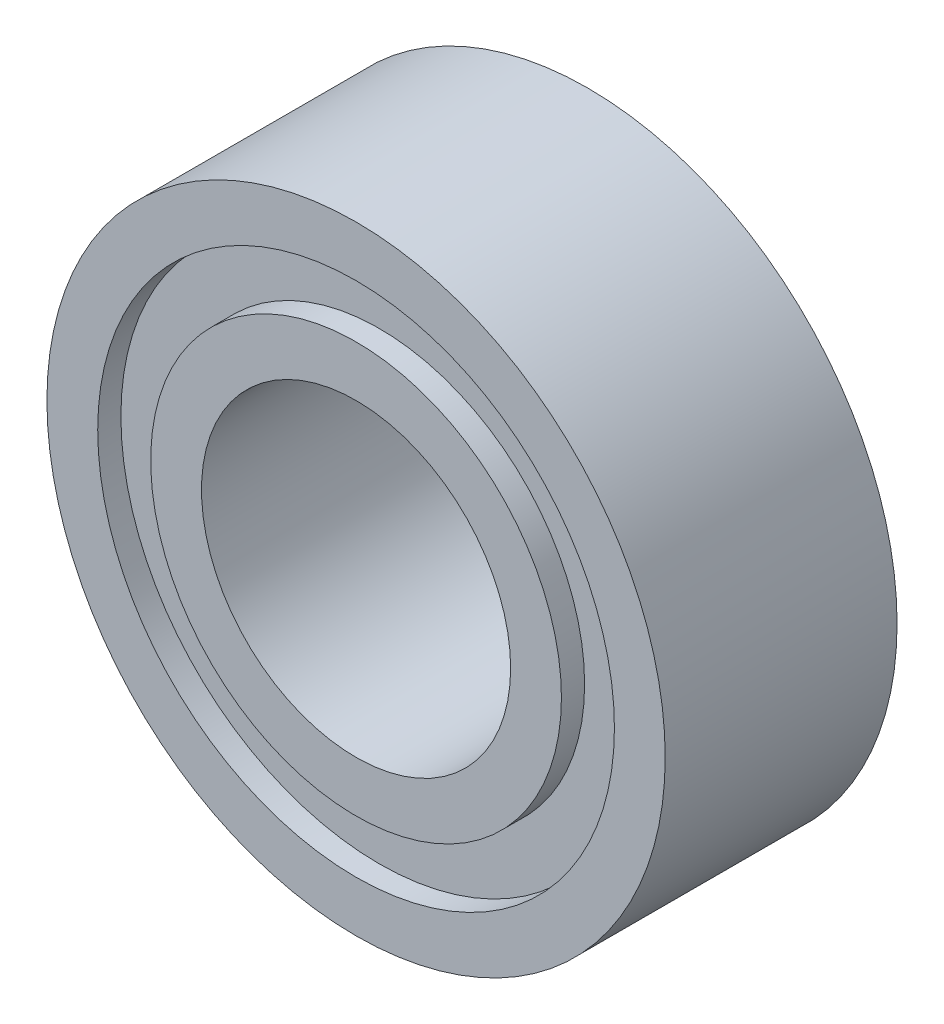
from build123d import *


with BuildPart() as part:
    # Эскиз1 → Повернуть1 (revolve)
    with BuildSketch(Plane(origin=(0, 0, 0), x_dir=(0, 0, -1), z_dir=(1, 0, 0))):
        Polygon((1.5, 2), (-1.5, 2), (-1.5, 2.657142857), (-1.2, 2.657142857), (-1.2, 3.342857143), (-1.5, 3.342857143), (-1.5, 4), (1.5, 4), (1.5, 3.342857143), (1.2, 3.342857143), (1.2, 2.657142857), (1.5, 2.657142857), align=None)
        with BuildLine():
            Line((0.492391084, 3.342857143), (1, 3.342857143))
            Line((1, 3.342857143), (1, 2.657142857))
            Line((1, 2.657142857), (0.492391084, 2.657142857))
            ThreePointArc((0.492391084, 2.657142857), (0, 2.4), (-0.492391084, 2.657142857))
            Line((-0.492391084, 2.657142857), (-1, 2.657142857))
            Line((-1, 2.657142857), (-1, 3.342857143))
            Line((-1, 3.342857143), (-0.492391084, 3.342857143))
            ThreePointArc((-0.492391084, 3.342857143), (0, 3.6), (0.492391084, 3.342857143))
        make_face(mode=Mode.SUBTRACT)
    revolve(axis=Axis((0, 0, 0), (0, 0, -1)))


solid = part.part
